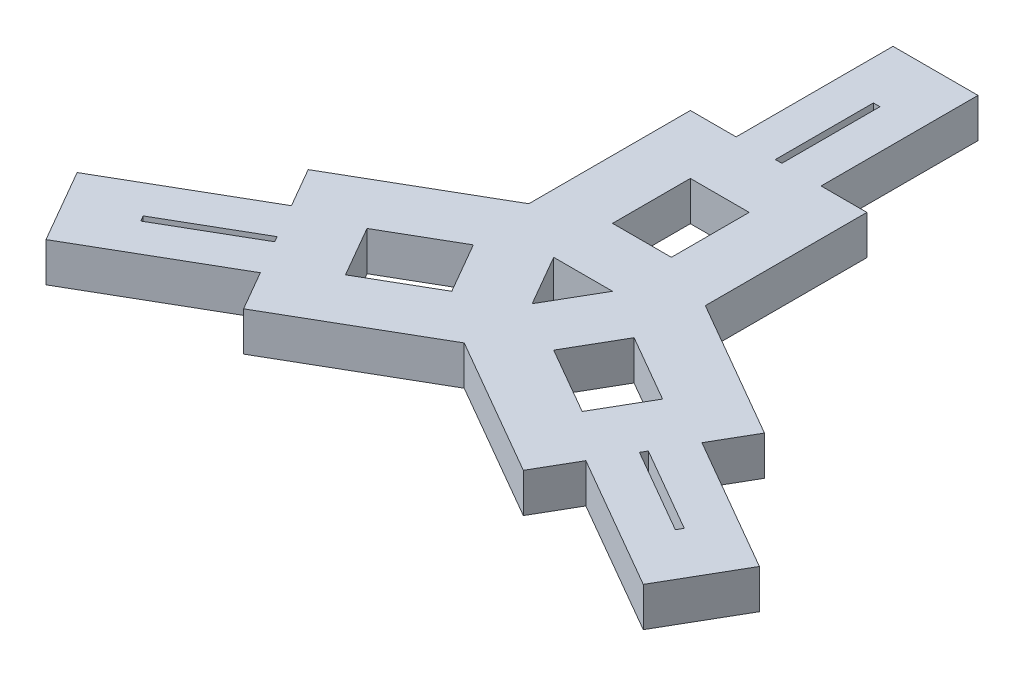
from build123d import *

# Parameters (mm, degrees)
CROQUIS1_W              = 90
CROQUIS1_H              = 119.019237886
CROQUIS1_W_2            = 10
CROQUIS1_H_2            = 150
SALIENTE_EXTRUIR1_DEPTH = 60


with BuildPart() as part:
    # Croquis1 → Saliente-Extruir1 (new body)
    with BuildSketch(Plane(origin=(0, 0, 0), x_dir=(1, 0, 0), z_dir=(0, 1, 0))):
        Polygon((-213.95825623, -279.413429511), (0, -155.884572681), (213.95825623, -279.413429511), (248.95825623, -218.791651246), (456.804353138, -338.791651246), (521.804353138, -226.208348754), (313.95825623, -106.208348754), (348.95825623, -45.586570489), (135, 77.942286341), (135, 325), (65, 325), (65, 565), (-65, 565), (-65, 325), (-135, 325), (-135, 77.942286341), (-348.95825623, -45.586570489), (-313.95825623, -106.208348754), (-521.804353138, -226.208348754), (-456.804353138, -338.791651246), (-248.95825623, -218.791651246), align=None)
        Polygon((278.95825623, -166.830127019), (283.95825623, -158.169872981), (348.910161514, -195.669872981), (413.862066798, -233.169872981), (408.862066798, -241.830127019), (343.910161514, -204.330127019), align=None, mode=Mode.SUBTRACT)
        Polygon((-408.862066798, -241.830127019), (-413.862066798, -233.169872981), (-283.95825623, -158.169872981), (-278.95825623, -166.830127019), align=None, mode=Mode.SUBTRACT)
        Polygon((-122.942286341, -19.019237886), (-77.942286341, -96.961524227), (-181.015969889, -156.47114317), (-226.015969889, -78.52885683), align=None, mode=Mode.SUBTRACT)
        Polygon((181.015969889, -156.47114317), (77.942286341, -96.961524227), (122.942286341, -19.019237886), (226.015969889, -78.52885683), align=None, mode=Mode.SUBTRACT)
        Polygon((0, -51.961524227), (-45, 25.980762114), (45, 25.980762114), align=None, mode=Mode.SUBTRACT)
        with Locations((0, 175.490381057)):
            Rectangle(CROQUIS1_W, CROQUIS1_H, mode=Mode.SUBTRACT)
        with Locations((0, 400)):
            Rectangle(CROQUIS1_W_2, CROQUIS1_H_2, mode=Mode.SUBTRACT)
    extrude(amount=SALIENTE_EXTRUIR1_DEPTH)


solid = part.part
